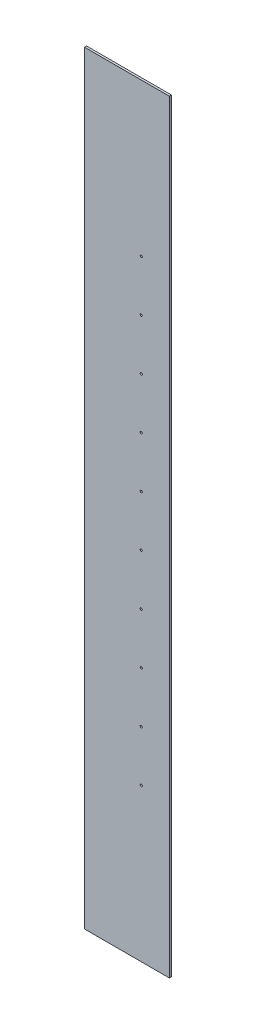
from build123d import *

# Parameters (mm, degrees)
SKETCH1_W           = 200
SKETCH1_H           = 1800
SKETCH1_R           = 2.5
BOSS_EXTRUDE1_DEPTH = 5


with BuildPart() as part:
    # Sketch1 → Boss-Extrude1 (new body)
    with BuildSketch(Plane.XY):
        Rectangle(SKETCH1_W, SKETCH1_H)
        with Locations((33.7, -540)):
            Circle(SKETCH1_R, mode=Mode.SUBTRACT)
        with Locations((33.7, -420)):
            Circle(SKETCH1_R, mode=Mode.SUBTRACT)
        with Locations((33.7, -300)):
            Circle(SKETCH1_R, mode=Mode.SUBTRACT)
        with Locations((33.7, -180)):
            Circle(SKETCH1_R, mode=Mode.SUBTRACT)
        with Locations((33.7, -60)):
            Circle(SKETCH1_R, mode=Mode.SUBTRACT)
        with Locations((33.7, 60)):
            Circle(SKETCH1_R, mode=Mode.SUBTRACT)
        with Locations((33.7, 180)):
            Circle(SKETCH1_R, mode=Mode.SUBTRACT)
        with Locations((33.7, 300)):
            Circle(SKETCH1_R, mode=Mode.SUBTRACT)
        with Locations((33.7, 420)):
            Circle(SKETCH1_R, mode=Mode.SUBTRACT)
        with Locations((33.7, 540)):
            Circle(SKETCH1_R, mode=Mode.SUBTRACT)
    extrude(amount=BOSS_EXTRUDE1_DEPTH)


solid = part.part
